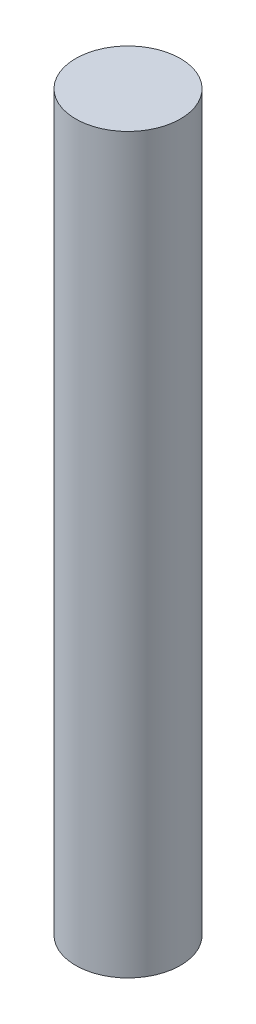
from build123d import *

# Parameters (mm, degrees)
SKETCH1_W = 7.5
SKETCH1_H = 105


with BuildPart() as part:
    # Sketch1 → Revolve1 (revolve)
    with BuildSketch(Plane.XY):
        with Locations((3.75, 52.5)):
            Rectangle(SKETCH1_W, SKETCH1_H)
    revolve(axis=Axis((0, 0, 0), (0, 1, 0)))


solid = part.part
